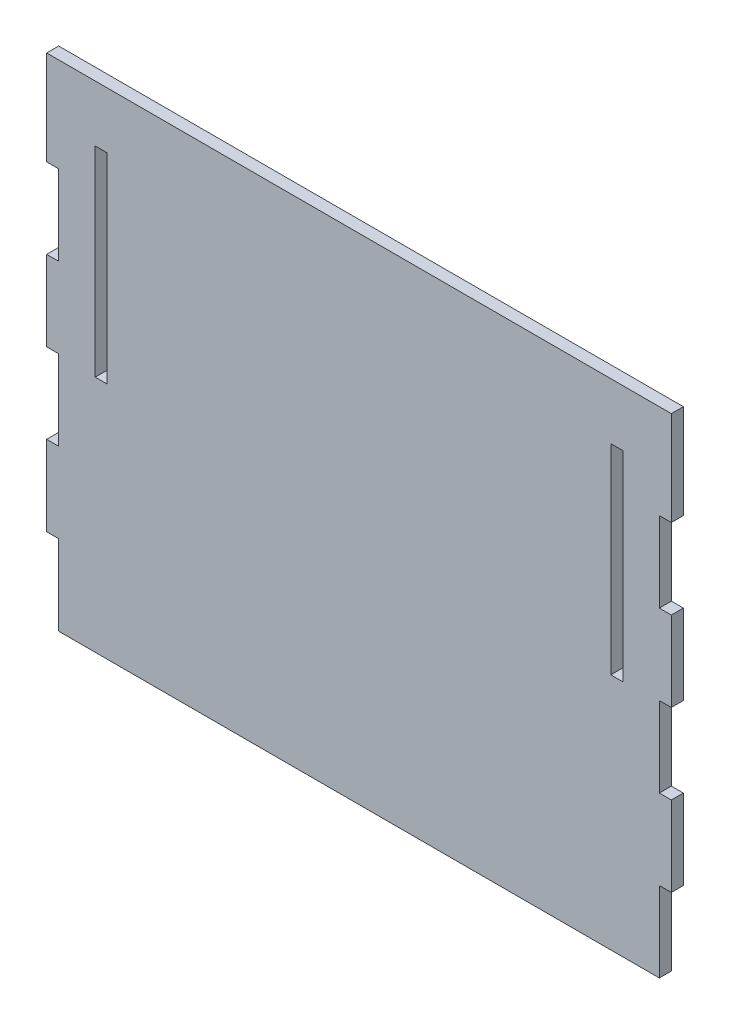
from build123d import *

# Parameters (mm, degrees)
SKETCH1_W           = 6
SKETCH1_H           = 100.000000002
BOSS_EXTRUDE1_DEPTH = 6


with BuildPart() as part:
    # Sketch1 → Boss-Extrude1 (new body)
    with BuildSketch(Plane.XY):
        Polygon((-302, 181.40990873), (-2, 181.409908735), (4, 181.409908735), (4, 134.306809003), (-2, 134.306809003), (-2, 94.306809003), (4, 94.306809003), (4, 54.306809003), (-2, 54.306809003), (-2, 14.306809003), (4, 14.306809003), (4, -25.693190997), (-2, -25.693190997), (-2, -65.693190997), (-302, -65.693190997), (-302, -25.693191002), (-308, -25.693191002), (-308, 14.306808998), (-302, 14.306808998), (-302, 54.306808998), (-308, 54.306808998), (-308, 94.306808998), (-302, 94.306808998), (-302, 134.306808998), (-308, 134.306808998), (-308, 181.40990873), align=None)
        with Locations((-280.75, 103.306809004)):
            Rectangle(SKETCH1_W, SKETCH1_H, mode=Mode.SUBTRACT)
        with Locations((-23.25, 103.306809004)):
            Rectangle(SKETCH1_W, SKETCH1_H, mode=Mode.SUBTRACT)
    extrude(amount=BOSS_EXTRUDE1_DEPTH)


solid = part.part
